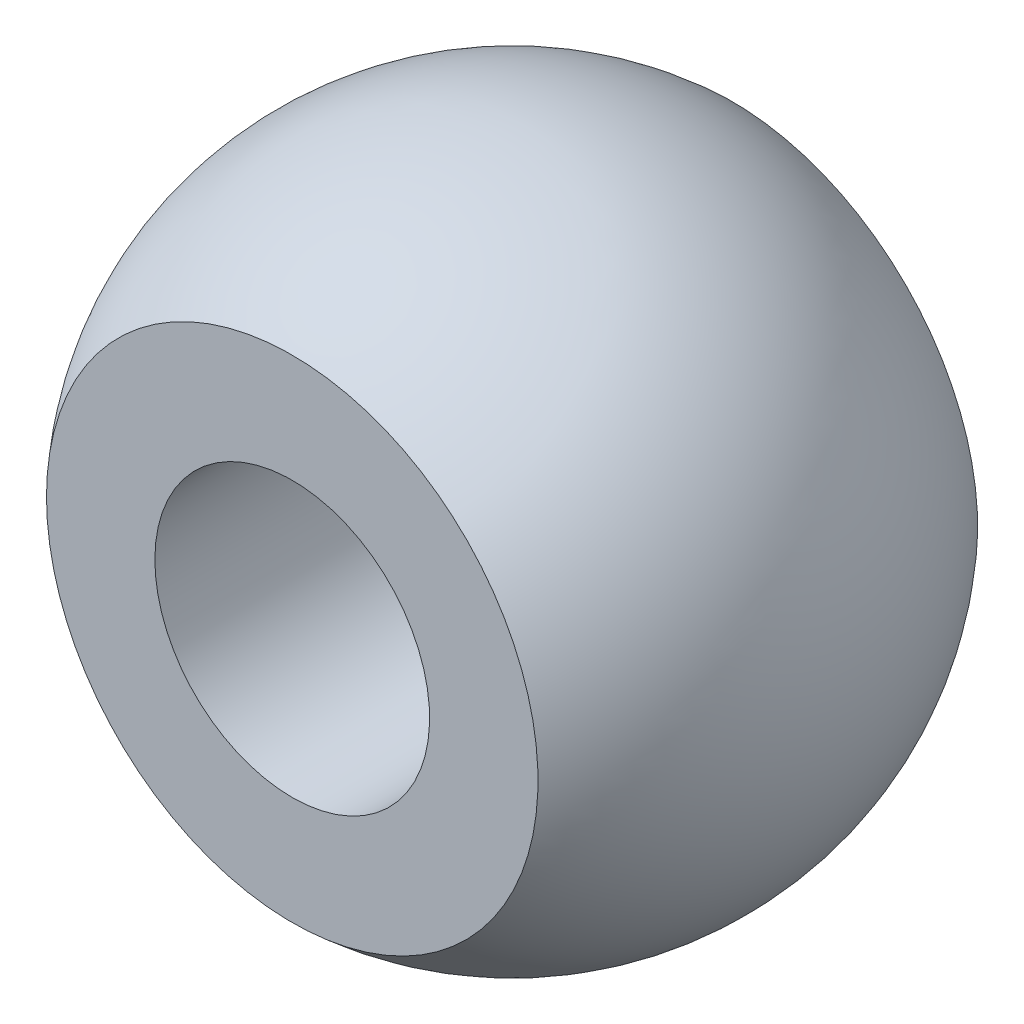
from build123d import *
from build123d.topology import SkipClean

# Parameters (mm, degrees)
CROQUIS2_R                 = 2.5
CORTAR_EXTRUIR1_DEPTH      = 11.392304845
CORTAR_EXTRUIR1_DEPTH_BACK = 11.392304845
CROQUIS3_W                 = 10
CROQUIS3_H                 = 8.94427191
CORTAR_EXTRUIR2_DEPTH      = 11.392304845
CORTAR_EXTRUIR2_DEPTH_BACK = 11.392304845


with BuildPart() as part:
    # Croquis1 → Revolución1 (revolve)
    with BuildSketch(Plane.XY):
        with BuildLine():
            Line((0, 6), (0, -6))
            ThreePointArc((0, -6), (-6, 0), (0, 6))
        make_face()
    revolve(axis=Axis((0, 6, 0), (0, -1, 0)))

    # Croquis2 → Cortar-Extruir1 (cut, two sides)
    with BuildSketch(Plane.XY) as cortar_extruir1_sk:
        with Locations(Location((0, 0, 0), (0, 0, 180))):
            Circle(CROQUIS2_R)
    extrude(amount=CORTAR_EXTRUIR1_DEPTH, mode=Mode.SUBTRACT)
    extrude(cortar_extruir1_sk.sketch, amount=-CORTAR_EXTRUIR1_DEPTH_BACK, mode=Mode.SUBTRACT)

    # Croquis3 → Cortar-Extruir2 (cut, two sides)
    with SkipClean():  # the faces are left unmerged after this step: merging them gives an invalid solid
        with BuildSketch(Plane(origin=(0, 0, 0), x_dir=(0, 0, -1), z_dir=(1, 0, 0))) as cortar_extruir2_sk:
            with Locations((-9, 0)):
                Rectangle(CROQUIS3_W, CROQUIS3_H)
            with Locations((9, 0)):
                Rectangle(CROQUIS3_W, CROQUIS3_H)
        extrude(amount=CORTAR_EXTRUIR2_DEPTH, mode=Mode.SUBTRACT)
        extrude(cortar_extruir2_sk.sketch, amount=-CORTAR_EXTRUIR2_DEPTH_BACK, mode=Mode.SUBTRACT)


solid = part.part
